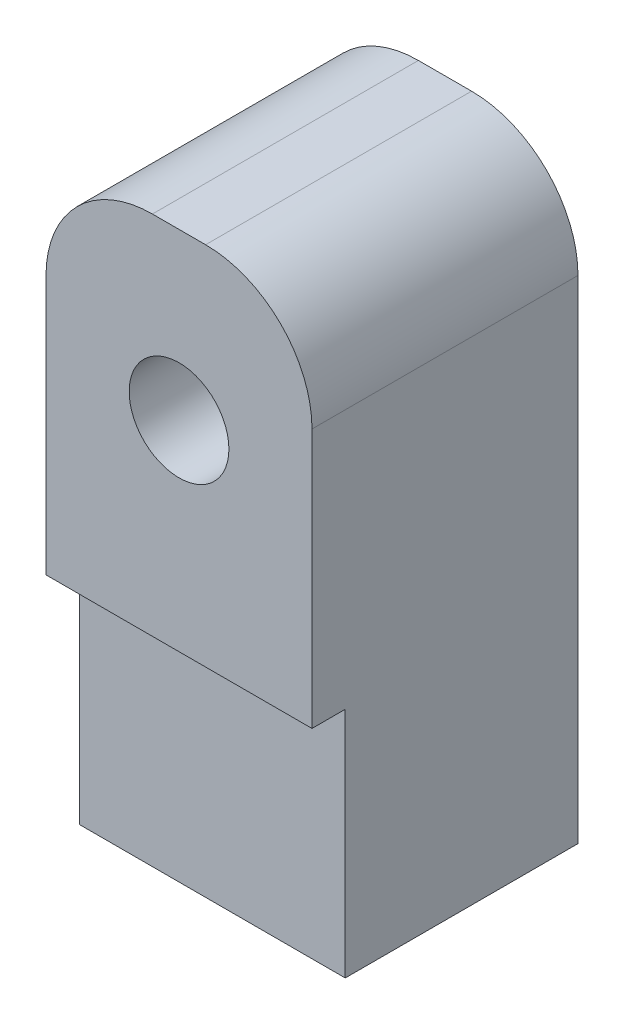
from build123d import *

# Parameters (mm, degrees)
SKETCH1_W           = 25.4
SKETCH1_H           = 25.4
BOSS_EXTRUDE1_DEPTH = 57.15
SKETCH2_W           = 25.4
SKETCH2_H           = 3.175
CUT_EXTRUDE1_DEPTH  = 22.225
SKETCH3_R           = 4.7625
CUT_EXTRUDE4_DEPTH  = 25.4
SKETCH4_R           = 6.0325
CUT_EXTRUDE5_DEPTH  = 3.175
SKETCH5_R           = 6.35
CUT_EXTRUDE6_DEPTH  = 30.1752
FILLET1_R           = 10.16


with BuildPart() as part:
    # Sketch1 → Boss-Extrude1 (new body)
    with BuildSketch(Plane(origin=(0, 0, 0), x_dir=(1, 0, 0), z_dir=(0, 1, 0))):
        Rectangle(SKETCH1_W, SKETCH1_H)
    extrude(amount=BOSS_EXTRUDE1_DEPTH)

    # Sketch2 → Cut-Extrude1 (cut)
    with BuildSketch(Plane.XZ):
        with Locations((0, 11.1125)):
            Rectangle(SKETCH2_W, SKETCH2_H)
    extrude(amount=-CUT_EXTRUDE1_DEPTH, mode=Mode.SUBTRACT)

    # Sketch3 → Cut-Extrude4 (cut)
    with BuildSketch(Plane.XY.offset(12.7)):
        with Locations((0.002085525, 41.362644983)):
            Circle(SKETCH3_R)
    extrude(amount=-CUT_EXTRUDE4_DEPTH, mode=Mode.SUBTRACT)

    # Sketch4 → Cut-Extrude5 (cut)
    with BuildSketch(Plane(origin=(0, 0, -12.7), x_dir=(-1, 0, 0), z_dir=(0, 0, -1))):
        with Locations((-0.002085525, 41.362644983)):
            Circle(SKETCH4_R)
    extrude(amount=-CUT_EXTRUDE5_DEPTH, mode=Mode.SUBTRACT)

    # Sketch5 → Cut-Extrude6 (cut)
    with BuildSketch(Plane.XZ):
        Circle(SKETCH5_R)
    extrude(amount=-CUT_EXTRUDE6_DEPTH, mode=Mode.SUBTRACT)

    # Fillet1
    fillet1_edges = [part.edges().sort_by_distance(p)[0] for p in [
        (-12.7, 57.15, 0),
        (12.7, 57.15, 0),
    ]]
    fillet(fillet1_edges, radius=FILLET1_R)


solid = part.part
